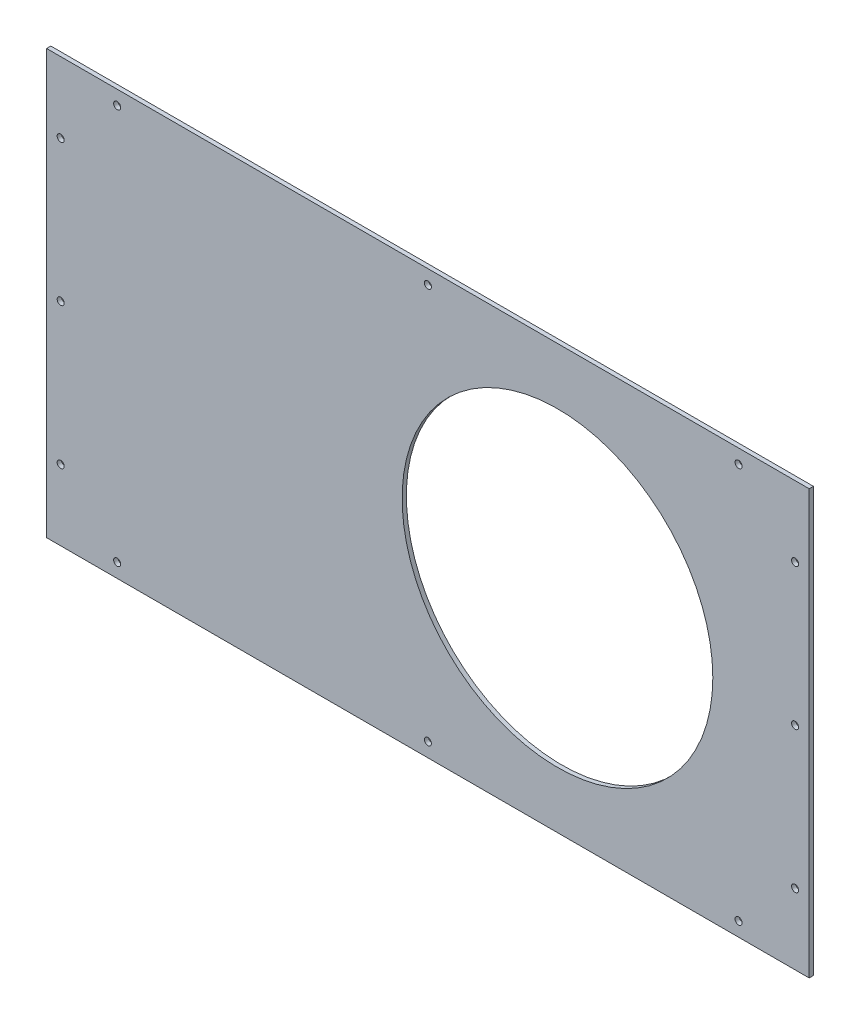
from build123d import *

# Parameters (mm, degrees)
CROQUIS1_W              = 540
CROQUIS1_H              = 300
SALIENTE_EXTRUIR1_DEPTH = 3
CROQUIS2_R              = 2.5
CORTAR_EXTRUIR1_DEPTH   = 4
CROQUIS3_R              = 110
CORTAR_EXTRUIR2_DEPTH   = 4


with BuildPart() as part:
    # Croquis1 → Saliente-Extruir1 (new body)
    with BuildSketch(Plane.XY):
        Rectangle(CROQUIS1_W, CROQUIS1_H)
    extrude(amount=SALIENTE_EXTRUIR1_DEPTH)

    # Croquis2 → Cortar-Extruir1 (cut, through all)
    with BuildSketch(Plane.XY.offset(3)):
        with Locations((0, 140)):
            Circle(CROQUIS2_R)
        with Locations((-220, 140)):
            Circle(CROQUIS2_R)
        with Locations((-260, 0)):
            Circle(CROQUIS2_R)
        with Locations((-260, 100)):
            Circle(CROQUIS2_R)
        with Locations((-260, -100)):
            Circle(CROQUIS2_R)
        with Locations((220, 140)):
            Circle(CROQUIS2_R)
        with Locations((260, -100)):
            Circle(CROQUIS2_R)
        with Locations((260, 0)):
            Circle(CROQUIS2_R)
        with Locations((260, 100)):
            Circle(CROQUIS2_R)
        with Locations((220, -140)):
            Circle(CROQUIS2_R)
        with Locations((0, -140)):
            Circle(CROQUIS2_R)
        with Locations((-220, -140)):
            Circle(CROQUIS2_R)
    extrude(amount=-CORTAR_EXTRUIR1_DEPTH, mode=Mode.SUBTRACT)

    # Croquis3 → Cortar-Extruir2 (cut, through all)
    with BuildSketch(Plane.XY.offset(3)):
        with Locations((91.756190819, 0)):
            Circle(CROQUIS3_R)
    extrude(amount=-CORTAR_EXTRUIR2_DEPTH, mode=Mode.SUBTRACT)


solid = part.part
